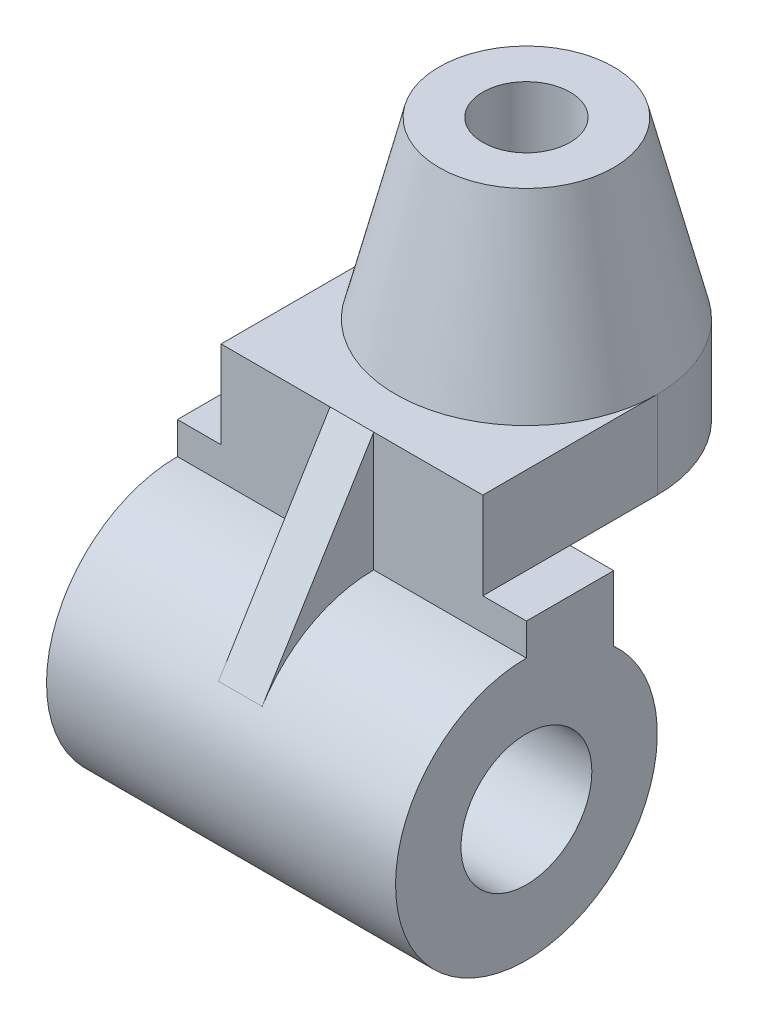
from build123d import *

# Parameters (mm, degrees)
SKETCH1_R                = 20
SKETCH2_R                = 30
SKETCH3_R                = 10
CUT_EXTRUDE1_DEPTH       = 59.30951912
BOSS_EXTRUDE1_DEPTH      = 20
SKETCH7_R                = 30
SKETCH7_R_2              = 15
BOSS_EXTRUDE2_DEPTH      = 10
BOSS_EXTRUDE2_DEPTH_BACK = 70
RIB1_REACH               = 152.734
SKETCH11_WALL_W          = 352.358184706
SKETCH11_WALL_H          = 10


with BuildPart() as part:
    # Sketch1 → Loft1 section 0
    with BuildSketch(Plane(origin=(0, 0, 0), x_dir=(1, 0, 0), z_dir=(0, 1, 0))):
        Circle(SKETCH1_R)
    # Sketch2 → Loft1 section 1
    with BuildSketch(Plane(origin=(0, -40, 0), x_dir=(1, 0, 0), z_dir=(0, 1, 0))):
        Circle(SKETCH2_R)
    loft()

    # Sketch3 → Cut-Extrude1 (cut, through all)
    with BuildSketch(Plane(origin=(0, 0, 0), x_dir=(1, 0, 0), z_dir=(0, 1, 0))):
        with Locations(Location((0, 0, 0), (0, 0, 270))):
            Circle(SKETCH3_R)
    extrude(amount=-CUT_EXTRUDE1_DEPTH, mode=Mode.SUBTRACT)

    # Sketch6 → Boss-Extrude1 (add)
    with BuildSketch(Plane(origin=(0, -40, 0), x_dir=(1, 0, 0), z_dir=(0, 1, 0))):
        with BuildLine():
            ThreePointArc((-30, 0), (0, 30), (30, 0))
            Line((30, 0), (30, -40))
            Line((30, -40), (-30, -40))
            Line((-30, -40), (-30, 0))
        make_face()
    extrude(amount=-BOSS_EXTRUDE1_DEPTH)

    # Sketch7 → Boss-Extrude2 (add, two sides)
    with BuildSketch(Plane(origin=(30, 0, 0), x_dir=(0, 0, -1), z_dir=(1, 0, 0))) as boss_extrude2_sk:
        with Locations((-40, -97.360679775)):
            Circle(SKETCH7_R)
        with Locations((-40, -97.360679775)):
            Circle(SKETCH7_R_2, mode=Mode.SUBTRACT)
        with BuildLine():
            Line((-20, -75), (-20, -60))
            Line((-20, -60), (-40, -60))
            Line((-40, -60), (-40, -67.360679775))
            ThreePointArc((-40, -67.360679775), (-29.295337307, -69.335509006), (-20, -75))
        make_face()
    extrude(amount=BOSS_EXTRUDE2_DEPTH)
    extrude(boss_extrude2_sk.sketch, amount=-BOSS_EXTRUDE2_DEPTH_BACK)

    # Sketch11 wall → Rib1 (add, up to next)
    with BuildSketch(Plane(origin=(0, -60.835244504, 52.784931695), x_dir=(0, -0.85232878253, 0.52300635414), z_dir=(0, -0.52300635414, -0.85232878253)), mode=Mode.PRIVATE) as rib1_sk1:
        Rectangle(SKETCH11_WALL_W, SKETCH11_WALL_H)
    rib1_tool1 = extrude(rib1_sk1.sketch, amount=RIB1_REACH, mode=Mode.PRIVATE) - part.part
    add(rib1_tool1.solids().sort_by_distance((0, -60.835244504, 52.784931695))[0])


solid = part.part
